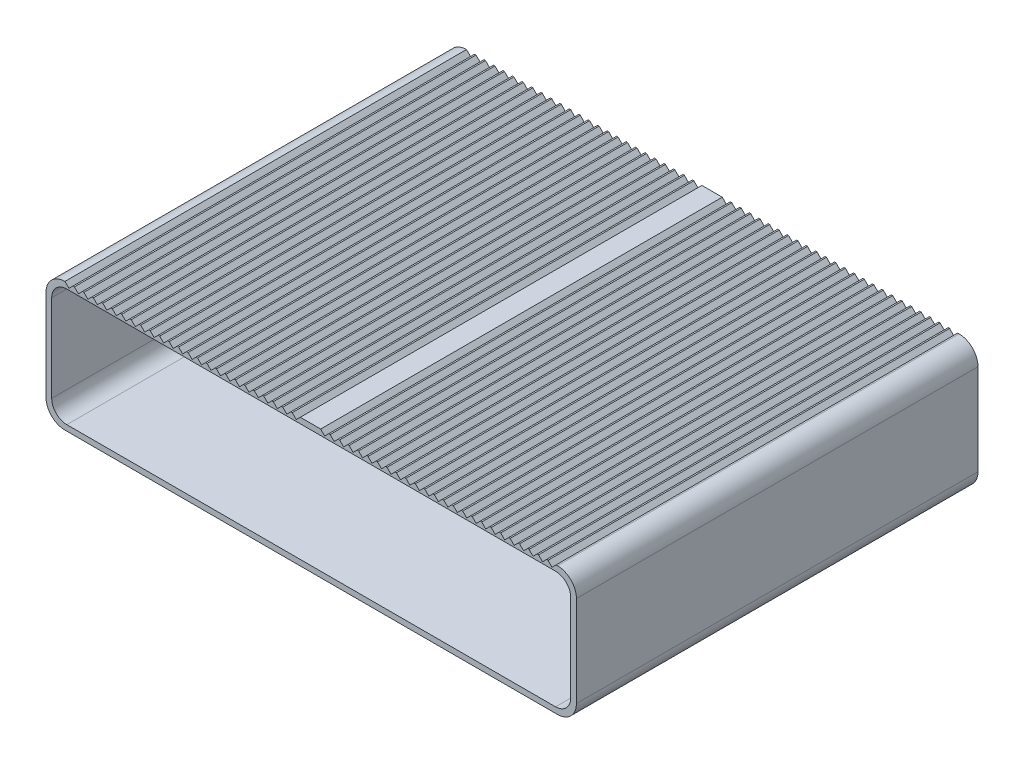
from build123d import *

# Parameters (mm, degrees)
BOSS_EXTRUDE1_DEPTH = 106


with BuildPart() as part:
    # Sketch1 → Boss-Extrude1 (new body)
    with BuildSketch(Plane.XY):
        with BuildLine():
            Line((-65, 17), (-63.939339828, 15.939339828))
            Line((-63.939339828, 15.939339828), (-62.878679656, 17))
            Line((-62.878679656, 17), (-62.5, 17))
            Line((-62.5, 17), (-61.439339828, 15.939339828))
            Line((-61.439339828, 15.939339828), (-60.378679656, 17))
            Line((-60.378679656, 17), (-60, 17))
            Line((-60, 17), (-58.939339828, 15.939339828))
            Line((-58.939339828, 15.939339828), (-57.878679656, 17))
            Line((-57.878679656, 17), (-57.5, 17))
            Line((-57.5, 17), (-56.439339828, 15.939339828))
            Line((-56.439339828, 15.939339828), (-55.378679656, 17))
            Line((-55.378679656, 17), (-55, 17))
            Line((-55, 17), (-53.939339828, 15.939339828))
            Line((-53.939339828, 15.939339828), (-52.878679656, 17))
            Line((-52.878679656, 17), (-52.5, 17))
            Line((-52.5, 17), (-51.439339828, 15.939339828))
            Line((-51.439339828, 15.939339828), (-50.378679656, 17))
            Line((-50.378679656, 17), (-50, 17))
            Line((-50, 17), (-48.939339828, 15.939339828))
            Line((-48.939339828, 15.939339828), (-47.878679656, 17))
            Line((-47.878679656, 17), (-47.5, 17))
            Line((-47.5, 17), (-46.439339828, 15.939339828))
            Line((-46.439339828, 15.939339828), (-45.378679656, 17))
            Line((-45.378679656, 17), (-45, 17))
            Line((-45, 17), (-43.939339828, 15.939339828))
            Line((-43.939339828, 15.939339828), (-42.878679656, 17))
            Line((-42.878679656, 17), (-42.5, 17))
            Line((-42.5, 17), (-41.439339828, 15.939339828))
            Line((-41.439339828, 15.939339828), (-40.378679656, 17))
            Line((-40.378679656, 17), (-40, 17))
            Line((-40, 17), (-38.939339828, 15.939339828))
            Line((-38.939339828, 15.939339828), (-37.878679656, 17))
            Line((-37.878679656, 17), (-37.5, 17))
            Line((-37.5, 17), (-36.439339828, 15.939339828))
            Line((-36.439339828, 15.939339828), (-35.378679656, 17))
            Line((-35.378679656, 17), (-35, 17))
            Line((-35, 17), (-33.939339828, 15.939339828))
            Line((-33.939339828, 15.939339828), (-32.878679656, 17))
            Line((-32.878679656, 17), (-32.5, 17))
            Line((-32.5, 17), (-31.439339828, 15.939339828))
            Line((-31.439339828, 15.939339828), (-30.378679656, 17))
            Line((-30.378679656, 17), (-30, 17))
            Line((-30, 17), (-28.939339828, 15.939339828))
            Line((-28.939339828, 15.939339828), (-27.878679656, 17))
            Line((-27.878679656, 17), (-27.5, 17))
            Line((-27.5, 17), (-26.439339828, 15.939339828))
            Line((-26.439339828, 15.939339828), (-25.378679656, 17))
            Line((-25.378679656, 17), (-25, 17))
            Line((-25, 17), (-23.939339828, 15.939339828))
            Line((-23.939339828, 15.939339828), (-22.878679656, 17))
            Line((-22.878679656, 17), (-22.5, 17))
            Line((-22.5, 17), (-21.439339828, 15.939339828))
            Line((-21.439339828, 15.939339828), (-20.378679656, 17))
            Line((-20.378679656, 17), (-20, 17))
            Line((-20, 17), (-18.939339828, 15.939339828))
            Line((-18.939339828, 15.939339828), (-17.878679656, 17))
            Line((-17.878679656, 17), (-17.5, 17))
            Line((-17.5, 17), (-16.439339828, 15.939339828))
            Line((-16.439339828, 15.939339828), (-15.378679656, 17))
            Line((-15.378679656, 17), (-15, 17))
            Line((-15, 17), (-13.939339828, 15.939339828))
            Line((-13.939339828, 15.939339828), (-12.878679656, 17))
            Line((-12.878679656, 17), (-12.5, 17))
            Line((-12.5, 17), (-11.439339828, 15.939339828))
            Line((-11.439339828, 15.939339828), (-10.378679656, 17))
            Line((-10.378679656, 17), (-10, 17))
            Line((-10, 17), (-8.939339828, 15.939339828))
            Line((-8.939339828, 15.939339828), (-7.878679656, 17))
            Line((-7.878679656, 17), (-7.5, 17))
            Line((-7.5, 17), (-6.439339828, 15.939339828))
            Line((-6.439339828, 15.939339828), (-5.378679656, 17))
            Line((-5.378679656, 17), (-5, 17))
            Line((-5, 17), (-3.939339828, 15.939339828))
            Line((-3.939339828, 15.939339828), (-2.878679656, 17))
            Line((-2.878679656, 17), (2.5, 17))
            Line((2.5, 17), (3.560660172, 15.939339828))
            Line((3.560660172, 15.939339828), (4.621320344, 17))
            Line((4.621320344, 17), (5, 17))
            Line((5, 17), (6.060660172, 15.939339828))
            Line((6.060660172, 15.939339828), (7.121320344, 17))
            Line((7.121320344, 17), (7.5, 17))
            Line((7.5, 17), (8.560660172, 15.939339828))
            Line((8.560660172, 15.939339828), (9.621320344, 17))
            Line((9.621320344, 17), (10, 17))
            Line((10, 17), (11.060660172, 15.939339828))
            Line((11.060660172, 15.939339828), (12.121320344, 17))
            Line((12.121320344, 17), (12.5, 17))
            Line((12.5, 17), (13.560660172, 15.939339828))
            Line((13.560660172, 15.939339828), (14.621320344, 17))
            Line((14.621320344, 17), (15, 17))
            Line((15, 17), (16.060660172, 15.939339828))
            Line((16.060660172, 15.939339828), (17.121320344, 17))
            Line((17.121320344, 17), (17.5, 17))
            Line((17.5, 17), (18.560660172, 15.939339828))
            Line((18.560660172, 15.939339828), (19.621320344, 17))
            Line((19.621320344, 17), (20, 17))
            Line((20, 17), (21.060660172, 15.939339828))
            Line((21.060660172, 15.939339828), (22.121320344, 17))
            Line((22.121320344, 17), (22.5, 17))
            Line((22.5, 17), (23.560660172, 15.939339828))
            Line((23.560660172, 15.939339828), (24.621320344, 17))
            Line((24.621320344, 17), (25, 17))
            Line((25, 17), (26.060660172, 15.939339828))
            Line((26.060660172, 15.939339828), (27.121320344, 17))
            Line((27.121320344, 17), (27.5, 17))
            Line((27.5, 17), (28.560660172, 15.939339828))
            Line((28.560660172, 15.939339828), (29.621320344, 17))
            Line((29.621320344, 17), (30, 17))
            Line((30, 17), (31.060660172, 15.939339828))
            Line((31.060660172, 15.939339828), (32.121320344, 17))
            Line((32.121320344, 17), (32.5, 17))
            Line((32.5, 17), (33.560660172, 15.939339828))
            Line((33.560660172, 15.939339828), (34.621320344, 17))
            Line((34.621320344, 17), (35, 17))
            Line((35, 17), (36.060660172, 15.939339828))
            Line((36.060660172, 15.939339828), (37.121320344, 17))
            Line((37.121320344, 17), (37.5, 17))
            Line((37.5, 17), (38.560660172, 15.939339828))
            Line((38.560660172, 15.939339828), (39.621320344, 17))
            Line((39.621320344, 17), (40, 17))
            Line((40, 17), (41.060660172, 15.939339828))
            Line((41.060660172, 15.939339828), (42.121320344, 17))
            Line((42.121320344, 17), (42.5, 17))
            Line((42.5, 17), (43.560660172, 15.939339828))
            Line((43.560660172, 15.939339828), (44.621320344, 17))
            Line((44.621320344, 17), (45, 17))
            Line((45, 17), (46.060660172, 15.939339828))
            Line((46.060660172, 15.939339828), (47.121320344, 17))
            Line((47.121320344, 17), (47.5, 17))
            Line((47.5, 17), (48.560660172, 15.939339828))
            Line((48.560660172, 15.939339828), (49.621320344, 17))
            Line((49.621320344, 17), (50, 17))
            Line((50, 17), (51.060660172, 15.939339828))
            Line((51.060660172, 15.939339828), (52.121320344, 17))
            Line((52.121320344, 17), (52.5, 17))
            Line((52.5, 17), (53.560660172, 15.939339828))
            Line((53.560660172, 15.939339828), (54.621320344, 17))
            Line((54.621320344, 17), (55, 17))
            Line((55, 17), (56.060660172, 15.939339828))
            Line((56.060660172, 15.939339828), (57.121320344, 17))
            Line((57.121320344, 17), (57.5, 17))
            Line((57.5, 17), (58.560660172, 15.939339828))
            Line((58.560660172, 15.939339828), (59.621320344, 17))
            Line((59.621320344, 17), (60, 17))
            Line((60, 17), (61.060660172, 15.939339828))
            Line((61.060660172, 15.939339828), (62.121320344, 17))
            Line((62.121320344, 17), (62.5, 17))
            Line((62.5, 17), (63.560660172, 15.939339828))
            Line((63.560660172, 15.939339828), (64.621320344, 17))
            Line((64.621320344, 17), (65, 17))
            ThreePointArc((65, 17), (68.535533906, 15.535533906), (70, 12))
            Line((70, 12), (70, -12))
            ThreePointArc((70, -12), (68.535533906, -15.535533906), (65, -17))
            Line((65, -17), (-65, -17))
            ThreePointArc((-65, -17), (-68.535533906, -15.535533906), (-70, -12))
            Line((-70, -12), (-70, 12))
            ThreePointArc((-70, 12), (-68.535533906, 15.535533906), (-65, 17))
        make_face()
        with BuildLine():
            Line((-64.5, 15.5), (64.5, 15.5))
            ThreePointArc((64.5, 15.5), (67.328427125, 14.328427125), (68.5, 11.5))
            Line((68.5, 11.5), (68.5, -11.5))
            ThreePointArc((68.5, -11.5), (67.328427125, -14.328427125), (64.5, -15.5))
            Line((64.5, -15.5), (-64.5, -15.5))
            ThreePointArc((-64.5, -15.5), (-67.328427125, -14.328427125), (-68.5, -11.5))
            Line((-68.5, -11.5), (-68.5, 11.5))
            ThreePointArc((-68.5, 11.5), (-67.328427125, 14.328427125), (-64.5, 15.5))
        make_face(mode=Mode.SUBTRACT)
    extrude(amount=BOSS_EXTRUDE1_DEPTH)


solid = part.part
